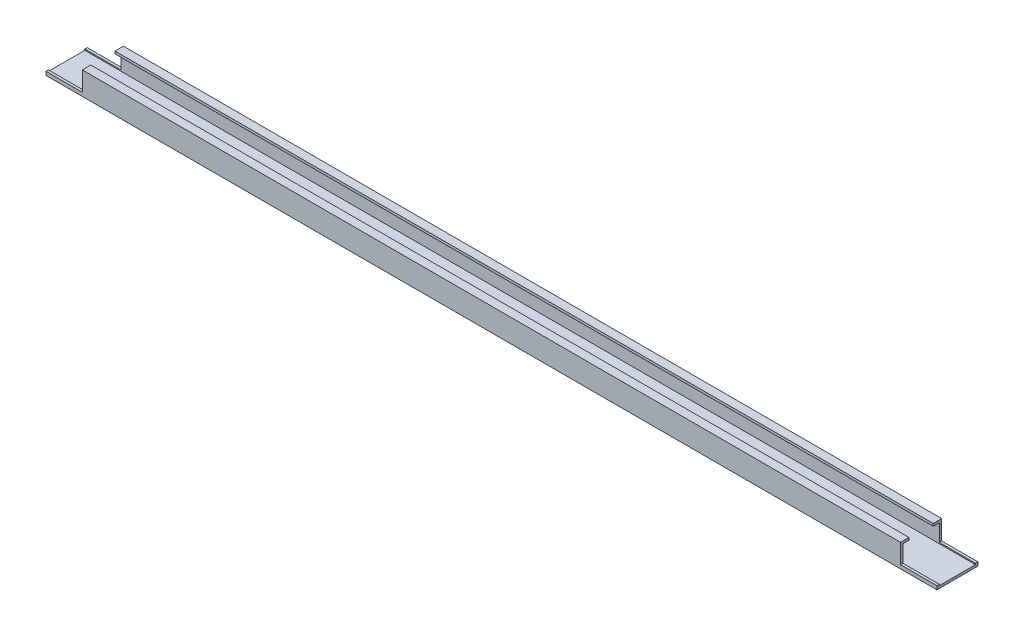
from build123d import *

# Parameters (mm, degrees)
EXTRUDE_1_DEPTH     = 736
SKETCH_2_W          = 30
SKETCH_2_H          = 16
CUT_EXTRUDE_1_DEPTH = 35


with BuildPart() as part:
    # Эскиз1 → Вытянуть-Тонкостенный1 (new body)
    with BuildSketch(Plane(origin=(0, 0, 0), x_dir=(0, 0, -1), z_dir=(1, 0, 0))):
        Polygon((-10, 15), (-15, 15), (-15, 0), (15, 0), (15, 15), (10, 15), (10, 17), (17, 17), (17, -2), (-17, -2), (-17, 17), (-10, 17), align=None)
    extrude(amount=EXTRUDE_1_DEPTH)

    # Эскиз2 → Вырез-Вытянуть1 (cut, through all)
    with BuildSketch(Plane(origin=(0, 0, -17), x_dir=(-1, 0, 0), z_dir=(0, 0, -1))):
        with Locations((-721, 9)):
            Rectangle(SKETCH_2_W, SKETCH_2_H)
        with Locations((-15, 9)):
            Rectangle(SKETCH_2_W, SKETCH_2_H)
    extrude(amount=-CUT_EXTRUDE_1_DEPTH, mode=Mode.SUBTRACT)


solid = part.part
